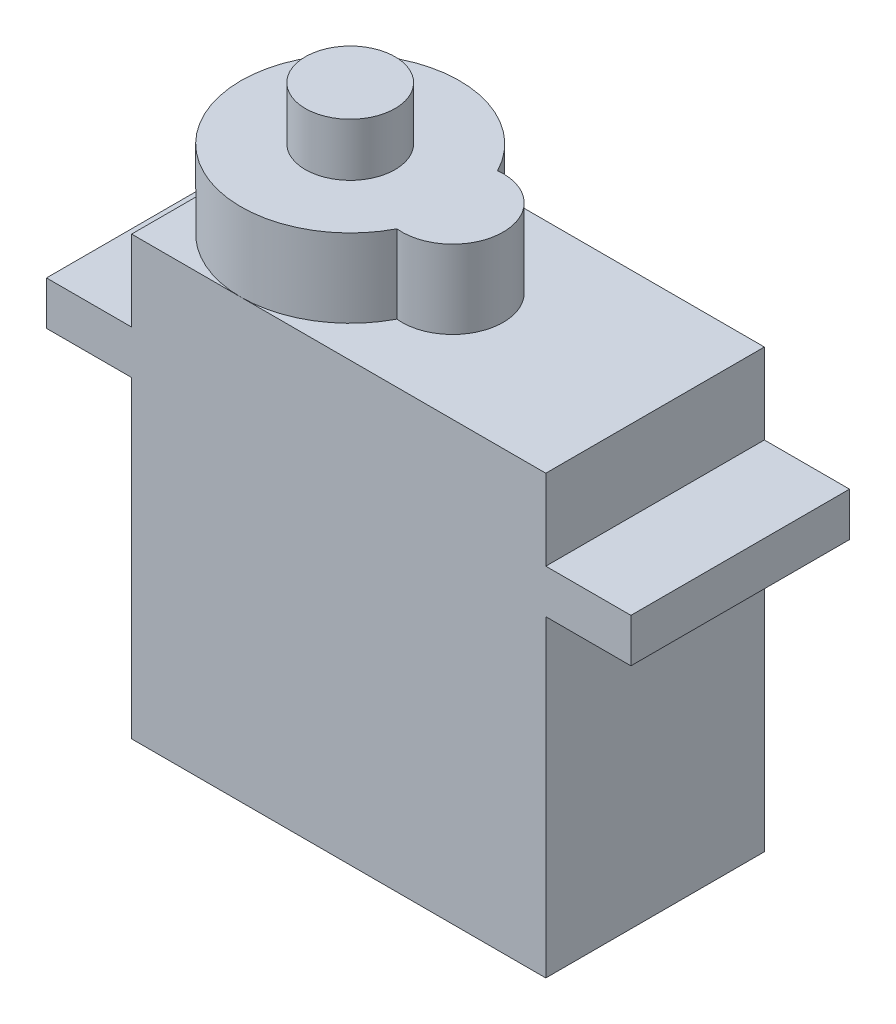
from build123d import *

# Parameters (mm, degrees)
BOSS_EXTRUDE1_DEPTH = 12.065
BOSS_EXTRUDE2_DEPTH = 4.318
SKETCH3_R           = 2.4765
BOSS_EXTRUDE3_DEPTH = 2.921


with BuildPart() as part:
    # Sketch1 → Boss-Extrude1 (new body)
    with BuildSketch(Plane.XY):
        Polygon((0, 0), (22.86, 0), (22.86, 17.272), (27.559, 17.272), (27.559, 19.685), (22.86, 19.685), (22.86, 24.13), (0, 24.13), (0, 19.685), (-4.699, 19.685), (-4.699, 17.272), (0, 17.272), align=None)
    extrude(amount=BOSS_EXTRUDE1_DEPTH)

    # Sketch2 → Boss-Extrude2 (add)
    with BuildSketch(Plane(origin=(0, 24.13, 0), x_dir=(1, 0, 0), z_dir=(0, 1, 0))):
        with BuildLine():
            ThreePointArc((11.387191011, -8.810690135), (14.478, -6.0325), (11.387191011, -3.254309865))
            ThreePointArc((11.387191011, -3.254309865), (0, -6.0325), (11.387191011, -8.810690135))
        make_face()
    extrude(amount=BOSS_EXTRUDE2_DEPTH)

    # Sketch3 → Boss-Extrude3 (add)
    with BuildSketch(Plane(origin=(0, 28.448, 0), x_dir=(1, 0, 0), z_dir=(0, 1, 0))):
        with Locations((6.0325, -6.0325)):
            Circle(SKETCH3_R)
    extrude(amount=BOSS_EXTRUDE3_DEPTH)


solid = part.part
